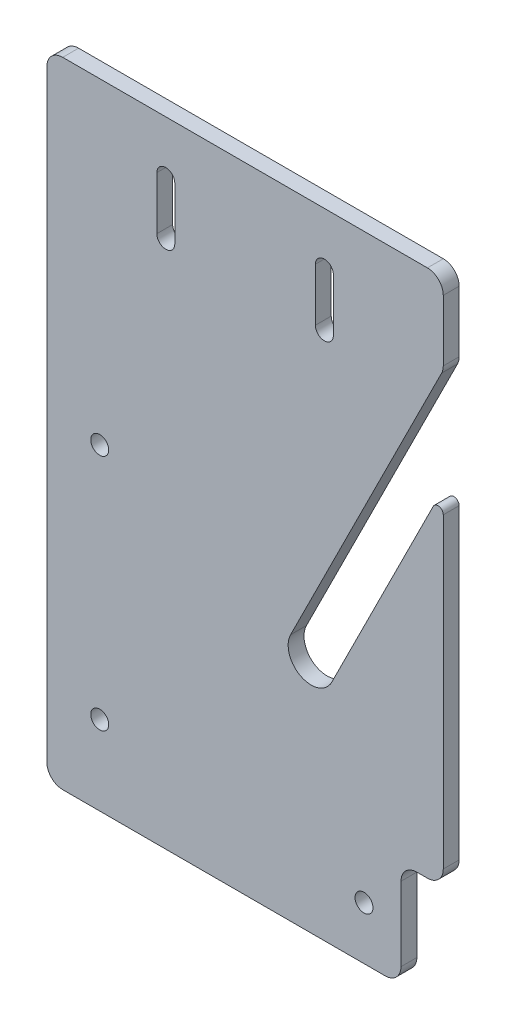
from build123d import *

# Parameters (mm, degrees)
SKETCH1_R           = 1.7
BOSS_EXTRUDE1_DEPTH = 3
FILLET1_R           = 3
CUT_EXTRUDE1_DEPTH  = 4
SKETCH3_W           = 8
SKETCH3_H           = 20
CUT_EXTRUDE2_DEPTH  = 4
FILLET2_R           = 3
FILLET3_R           = 1


with BuildPart() as part:
    # Sketch1 → Boss-Extrude1 (new body)
    with BuildSketch(Plane.XY):
        with BuildLine():
            Line((75, 0), (0, 0))
            Line((0, 0), (0, -120))
            Line((0, -120), (75, -120))
            Line((75, -120), (75, -34.726895702))
            Line((75, -34.726895702), (63.890758281, -56.94537914))
            Line((63.890758281, -56.94537914), (53.890758281, -76.94537914))
            ThreePointArc((53.890758281, -76.94537914), (48.05462086, -78.890758281), (46.109241719, -73.05462086))
            Line((46.109241719, -73.05462086), (56.109241719, -53.05462086))
            Line((56.109241719, -53.05462086), (75, -15.273104298))
            Line((75, -15.273104298), (75, 0))
        make_face()
        with Locations((10, -105)):
            Circle(SKETCH1_R, mode=Mode.SUBTRACT)
        with Locations((60, -110)):
            Circle(SKETCH1_R, mode=Mode.SUBTRACT)
        with Locations((10, -60)):
            Circle(SKETCH1_R, mode=Mode.SUBTRACT)
    extrude(amount=BOSS_EXTRUDE1_DEPTH)

    # Fillet1
    fillet1_edges = [part.edges().sort_by_distance(p)[0] for p in [
        (75, -120, 1.5),
        (0, -120, 1.5),
        (0, 0, 1.5),
        (75, 0, 1.5),
        (75, -15.273104298, 1.5),
    ]]
    fillet(fillet1_edges, radius=FILLET1_R)

    # Sketch2 → Cut-Extrude1 (cut, through all)
    with BuildSketch(Plane.XY.offset(3)):
        with BuildLine():
            Line((20.8, -10), (20.8, -20))
            ThreePointArc((20.8, -20), (22.5, -21.7), (24.2, -20))
            Line((24.2, -20), (24.2, -10))
            ThreePointArc((24.2, -10), (22.5, -8.3), (20.8, -10))
        make_face()
        with BuildLine():
            Line((50.8, -10), (50.8, -20))
            ThreePointArc((50.8, -20), (52.5, -21.7), (54.2, -20))
            Line((54.2, -20), (54.2, -10))
            ThreePointArc((54.2, -10), (52.5, -8.3), (50.8, -10))
        make_face()
    extrude(amount=-CUT_EXTRUDE1_DEPTH, mode=Mode.SUBTRACT)

    # Sketch3 → Cut-Extrude2 (cut, through all)
    with BuildSketch(Plane.XY.offset(3)):
        with Locations((71, -110)):
            Rectangle(SKETCH3_W, SKETCH3_H)
    extrude(amount=-CUT_EXTRUDE2_DEPTH, mode=Mode.SUBTRACT)

    # Fillet2
    fillet2_edges = [part.edges().sort_by_distance(p)[0] for p in [
        (75, -100, 1.5),
        (67, -120, 1.5),
        (67, -100, 1.5),
    ]]
    fillet(fillet2_edges, radius=FILLET2_R)

    # Fillet3
    fillet3_edges = [part.edges().sort_by_distance(p)[0] for p in [
        (75, -34.726895702, 1.5),
    ]]
    fillet(fillet3_edges, radius=FILLET3_R)


solid = part.part
